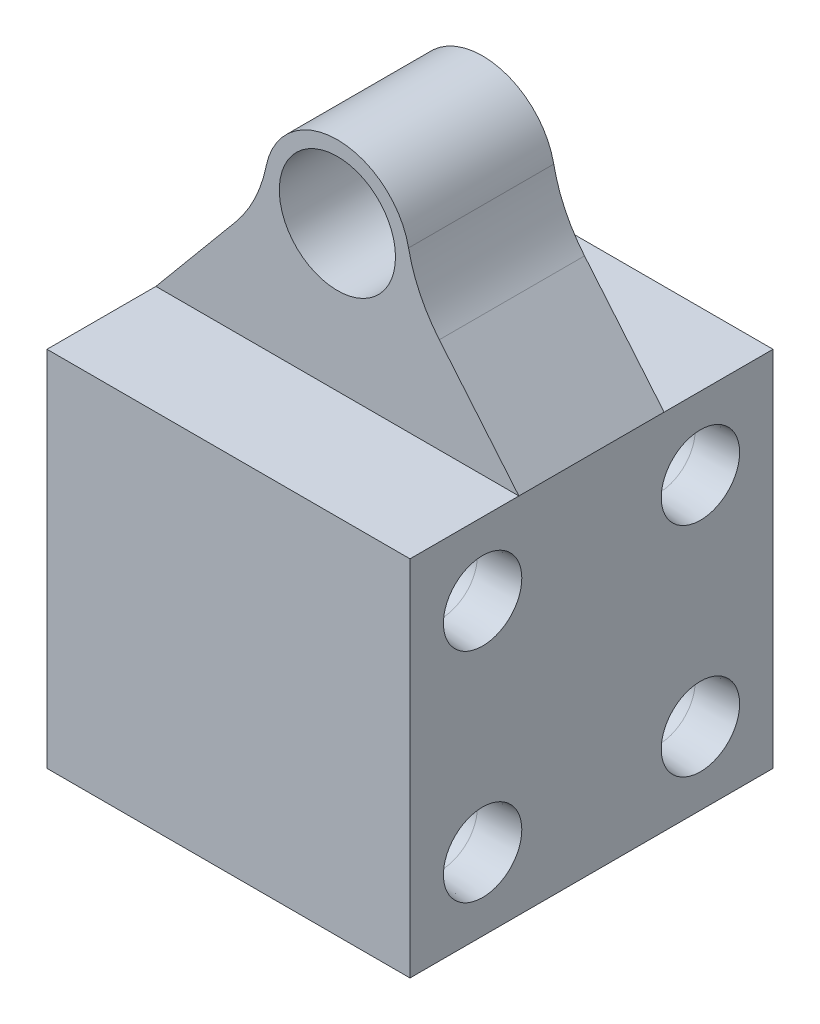
from build123d import *

# Parameters (mm, degrees)
SKETCH2_W                = 25
SKETCH2_H                = 25
BOSS_EXTRUDE1_DEPTH      = 25
LPATTERN1_COUNT          = 2
LPATTERN1_PITCH          = 15
LPATTERN1_COUNT_DIR2     = 2
LPATTERN1_PITCH_DIR2     = 15
SKETCH6_R                = 4
BOSS_EXTRUDE3_DEPTH      = 5
BOSS_EXTRUDE3_DEPTH_BACK = 5
FILLET4_R                = 10


with BuildPart() as part:
    # Sketch2 → Boss-Extrude1 (new body)
    with BuildSketch(Plane(origin=(0, 0, 0), x_dir=(1, 0, 0), z_dir=(0, 1, 0))):
        Rectangle(SKETCH2_W, SKETCH2_H)
    extrude(amount=BOSS_EXTRUDE1_DEPTH)

    # Sketch4 → CSK for M3 Oval Head Machine Screw1 (revolve, cut)
    with BuildSketch(Plane(origin=(-12.5, 20, -7.5), x_dir=(0, 0, 1), z_dir=(0, 1, 0))):
        Polygon((0, 0), (0, 11.502151548), (2.5, 10), (2.5, 2.860133251), (2.7, 0), align=None)
    csk_for_m3_oval_head_machine_screw1 = revolve(axis=Axis((-18.85, 20, -7.5), (1, 0, 0)), mode=Mode.SUBTRACT)

    # LPattern1: CSK for M3 Oval Head Machine Screw1 2 × 2
    with Locations(*[(0, -i * LPATTERN1_PITCH, j * LPATTERN1_PITCH_DIR2) for i in range(LPATTERN1_COUNT) for j in range(LPATTERN1_COUNT_DIR2) if (i, j) != (0, 0)]):
        add(csk_for_m3_oval_head_machine_screw1, mode=Mode.SUBTRACT)

    # Mirror1: CSK for M3 Oval Head Machine Screw1 across plane
    add(csk_for_m3_oval_head_machine_screw1.mirror(Plane(origin=(0, 0, 0), x_dir=(0, 0, 1), z_dir=(1, 0, 0))), mode=Mode.SUBTRACT)

    # Mirror1 copy 1 sketch → Mirror1 copy 1 (revolve, cut)
    with BuildSketch(Plane(origin=(12.5, 20, 7.5), x_dir=(0, 0, 1), z_dir=(0, 1, 0))):
        Polygon((0, 0), (0, -11.502151548), (2.5, -10), (2.5, -2.860133251), (2.7, 0), align=None)
    revolve(axis=Axis((18.85, 20, 7.5), (1, 0, 0)), mode=Mode.SUBTRACT)

    # Mirror1 copy 2 sketch → Mirror1 copy 2 (revolve, cut)
    with BuildSketch(Plane(origin=(12.5, 5, -7.5), x_dir=(0, 0, 1), z_dir=(0, 1, 0))):
        Polygon((0, 0), (0, -11.502151548), (2.5, -10), (2.5, -2.860133251), (2.7, 0), align=None)
    revolve(axis=Axis((18.85, 5, -7.5), (1, 0, 0)), mode=Mode.SUBTRACT)

    # Mirror1 copy 3 sketch → Mirror1 copy 3 (revolve, cut)
    with BuildSketch(Plane(origin=(12.5, 5, 7.5), x_dir=(0, 0, 1), z_dir=(0, 1, 0))):
        Polygon((0, 0), (0, -11.502151548), (2.5, -10), (2.5, -2.860133251), (2.7, 0), align=None)
    revolve(axis=Axis((18.85, 5, 7.5), (1, 0, 0)), mode=Mode.SUBTRACT)

    # Sketch6 → Boss-Extrude3 (add, two sides)
    with BuildSketch(Plane.XY) as boss_extrude3_sk:
        with BuildLine():
            ThreePointArc((4.918032787, 34.098360656), (0, 40), (-4.918032787, 34.098360656))
            Line((-4.918032787, 34.098360656), (-12.5, 25))
            Line((-12.5, 25), (12.5, 25))
            Line((12.5, 25), (4.918032787, 34.098360656))
        make_face()
        with Locations((0, 35)):
            Circle(SKETCH6_R, mode=Mode.SUBTRACT)
    extrude(amount=BOSS_EXTRUDE3_DEPTH)
    extrude(boss_extrude3_sk.sketch, amount=-BOSS_EXTRUDE3_DEPTH_BACK)

    # Fillet4
    fillet4_edges = [part.edges().sort_by_distance(p)[0] for p in [
        (-4.918032787, 34.098360656, 0),
        (4.918032787, 34.098360656, 0),
    ]]
    fillet(fillet4_edges, radius=FILLET4_R)


solid = part.part
